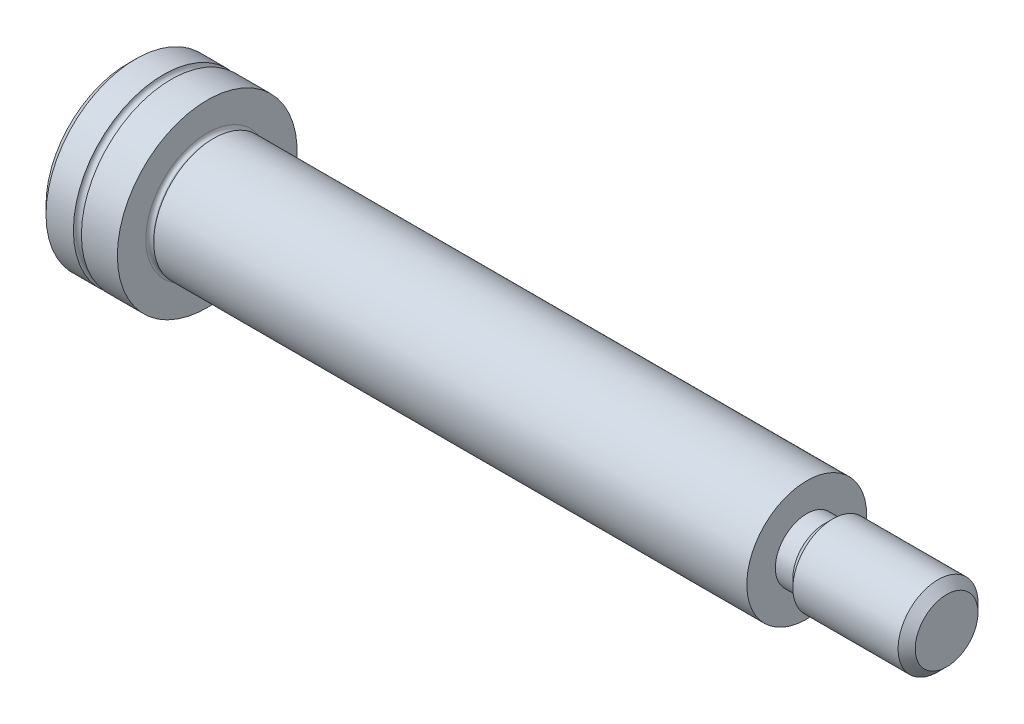
from build123d import *

# Parameters (mm, degrees)
SKETCH2_R           = 2.88
BOSS_EXTRUDE1_DEPTH = 0.250717968
SKETCH3_R           = 2.88
BOSS_EXTRUDE2_DEPTH = 0.069282032
BOSS_EXTRUDE2_TAPER = -59.999999992
SKETCH4_R           = 3
BOSS_EXTRUDE3_DEPTH = 29.68
SKETCH5_R           = 1.5705
BOSS_EXTRUDE4_DEPTH = 0.875
SKETCH6_R           = 1.5705
BOSS_EXTRUDE5_DEPTH = 0.4295
BOSS_EXTRUDE5_TAPER = -45
SKETCH7_R           = 2
BOSS_EXTRUDE6_DEPTH = 5.6955
CUT_EXTRUDE1_DEPTH  = 2
CHAMFER1_SIZE       = 0.4295
FILLET1_R           = 0.195


with BuildPart() as part:
    # Sketch1 → Revolve1 (revolve)
    with BuildSketch(Plane(origin=(0, 0, 0), x_dir=(-1, 0, 0), z_dir=(0, 0, -1))):
        with BuildLine():
            Line((0, 4.5), (0, 0))
            Line((0, 0), (4, 0))
            Line((4, 0), (4, 4.5))
            Line((4, 4.5), (2.2, 4.5))
            ThreePointArc((2.2, 4.5), (2, 4.3), (1.8, 4.5))
            Line((1.8, 4.5), (0, 4.5))
        make_face()
    revolve(axis=Axis((0, 0, 0), (-1, 0, 0)))

    # Sketch2 → Boss-Extrude1 (add)
    with BuildSketch(Plane(origin=(0, 0, 0), x_dir=(0, 0, -1), z_dir=(1, 0, 0))):
        Circle(SKETCH2_R)
    extrude(amount=BOSS_EXTRUDE1_DEPTH)

    # Sketch3 → Boss-Extrude2 (add)
    with BuildSketch(Plane(origin=(0.250717968, 0, 0), x_dir=(0, 0, -1), z_dir=(1, 0, 0))):
        Circle(SKETCH3_R)
    extrude(amount=BOSS_EXTRUDE2_DEPTH, taper=BOSS_EXTRUDE2_TAPER)

    # Sketch4 → Boss-Extrude3 (add)
    with BuildSketch(Plane(origin=(0.32, 0, 0), x_dir=(0, 0, -1), z_dir=(1, 0, 0))):
        Circle(SKETCH4_R)
    extrude(amount=BOSS_EXTRUDE3_DEPTH)

    # Sketch5 → Boss-Extrude4 (add)
    with BuildSketch(Plane(origin=(30, 0, 0), x_dir=(0, 0, -1), z_dir=(1, 0, 0))):
        Circle(SKETCH5_R)
    extrude(amount=BOSS_EXTRUDE4_DEPTH)

    # Sketch6 → Boss-Extrude5 (add)
    with BuildSketch(Plane(origin=(30.875, 0, 0), x_dir=(0, 0, -1), z_dir=(1, 0, 0))):
        Circle(SKETCH6_R)
    extrude(amount=BOSS_EXTRUDE5_DEPTH, taper=BOSS_EXTRUDE5_TAPER)

    # Sketch7 → Boss-Extrude6 (add)
    with BuildSketch(Plane(origin=(31.3045, 0, 0), x_dir=(0, 0, -1), z_dir=(1, 0, 0))):
        Circle(SKETCH7_R)
    extrude(amount=BOSS_EXTRUDE6_DEPTH)

    # Sketch8 → Cut-Extrude1 (cut)
    with BuildSketch(Plane.ZY.offset(4)):
        Polygon((1.5, -0.866025404), (1.5, 0.866025404), (0, 1.732050808), (-1.5, 0.866025404), (-1.5, -0.866025404), (0, -1.732050808), align=None)
    extrude(amount=-CUT_EXTRUDE1_DEPTH, mode=Mode.SUBTRACT)

    # Sketch9 → Cut-Revolve1 (revolve, cut)
    with BuildSketch(Plane.XY):
        Polygon((-2, 1.44), (-2, 0), (-1.168615612, 0), align=None)
    revolve(axis=Axis((-2, 0, 0), (1, 0, 0)), mode=Mode.SUBTRACT)

    # Chamfer1
    chamfer1_edges = [part.edges().sort_by_distance(p)[0] for p in [
        (37, 0, 2),
        (-4, -4.5, 0),
    ]]
    chamfer(chamfer1_edges, length=CHAMFER1_SIZE)

    # Fillet1
    fillet1_edges = [part.edges().sort_by_distance(p)[0] for p in [
        (0, 0, 2.88),
    ]]
    fillet(fillet1_edges, radius=FILLET1_R)


solid = part.part
